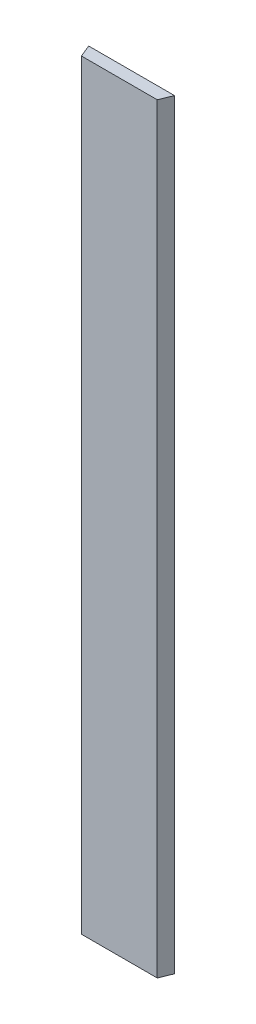
from build123d import *

# Parameters (mm, degrees)
BOSS_EXTRU_1_DEPTH = 310


with BuildPart() as part:
    # Esquisse1 → Boss.-Extru.1 (new body)
    with BuildSketch(Plane(origin=(0, 0, 0), x_dir=(1, 0, 0), z_dir=(0, 1, 0))):
        Polygon((0, 0), (30.89, 0), (32.945, 5), (-2.055, 5), align=None)
    extrude(amount=BOSS_EXTRU_1_DEPTH)


solid = part.part
